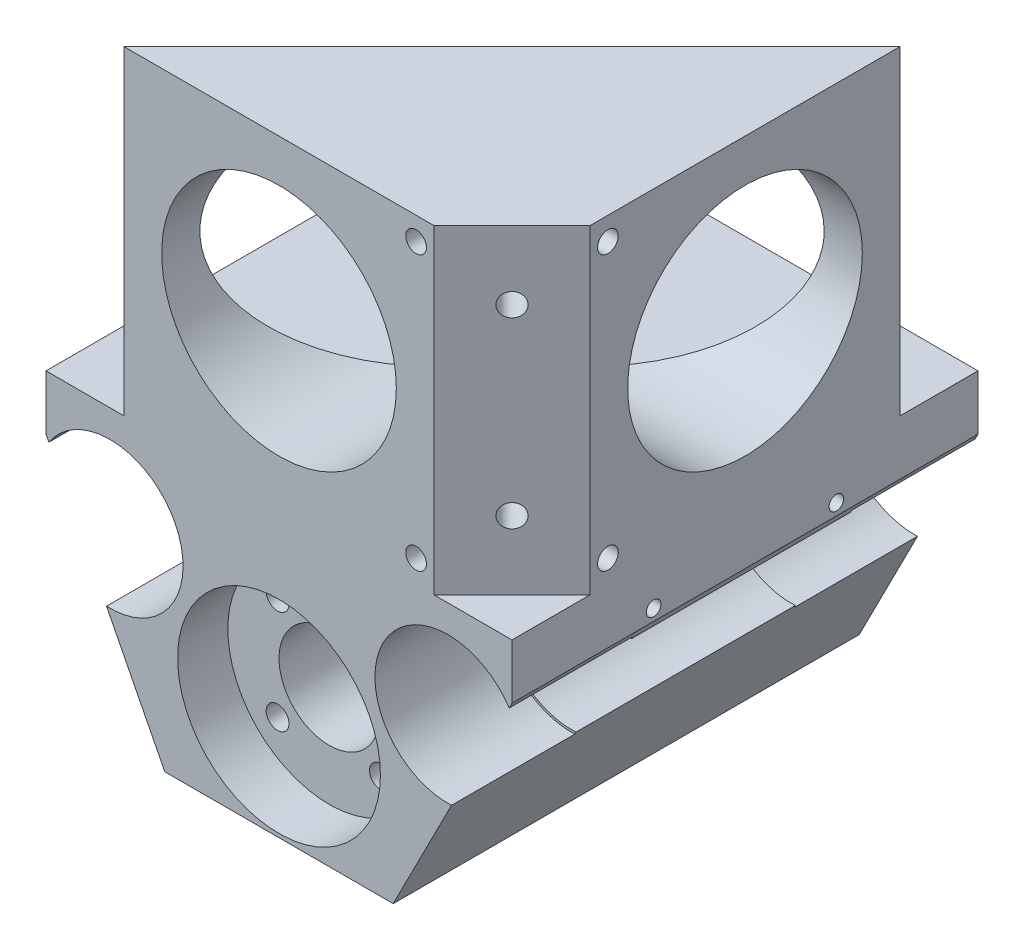
from build123d import *

# Parameters (mm, degrees)
BOSS_EXTRUDE1_DEPTH        = 51
CUT_EXTRUDE1_REACH         = 53
SKETCH2_R                  = 7.75
CUT_EXTRUDE2_REACH         = 53
SKETCH6_R                  = 5.5
M3_TAPPED_HOLE2_D          = 2.5
M3_TAPPED_HOLE2_DEPTH      = 11.5
M3_TAPPED_HOLE2_TIP        = 0.751075774
SKETCH13_R                 = 10.5
CUT_EXTRUDE5_DEPTH         = 15
BOSS_EXTRUDE2_DEPTH        = 35
CUT_EXTRUDE6_REACH         = 53
SKETCH24_R                 = 12.8397
CUT_EXTRUDE7_REACH         = 53
SKETCH25_R                 = 12.8397
M2_TAPPED_HOLE1_D          = 1.6
M2_TAPPED_HOLE1_DEPTH      = 3.2
M2_TAPPED_HOLE1_TIP        = 0.480688495
M3_TAPPED_HOLE4_D          = 2.5
M3_TAPPED_HOLE4_DEPTH      = 7.5
M3_TAPPED_HOLE4_TIP        = 0.751075774
M2_TAPPED_HOLE2_AT_2_COUNT = 2
M2_TAPPED_HOLE2_AT_2_PITCH = 20
SKETCH38_R                 = 11.1
CUT_EXTRUDE8_DEPTH         = 5.5
SKETCH39_R                 = 8
CUT_EXTRUDE9_DEPTH         = 13.5
SKETCH41_R                 = 8
CUT_EXTRUDE10_DEPTH        = 13.5
F_4_40_TAPPED_HOLE1_D      = 2.2606
F_4_40_TAPPED_HOLE1_DEPTH  = 7.59
F_4_40_TAPPED_HOLE1_TIP    = 0.679152758
F_4_40_TAPPED_HOLE2_D      = 2.2606
F_4_40_TAPPED_HOLE2_DEPTH  = 7.6
F_4_40_TAPPED_HOLE2_TIP    = 0.679152758


with BuildPart() as part:
    # Sketch1 → Boss-Extrude1 (new body)
    with BuildSketch(Plane.XY):
        Polygon((-25.5, 0), (25.5, 0), (25.5, -6), (12.5, -31.5), (-12.5, -31.5), (-25.5, -6), align=None)
    extrude(amount=BOSS_EXTRUDE1_DEPTH)

    # Sketch2 → Cut-Extrude1 (cut, up to next)
    with BuildSketch(Plane.XY.offset(51), mode=Mode.PRIVATE) as cut_extrude1_sk1:
        with Locations((-18.5, -11)):
            Circle(SKETCH2_R)
    cut_extrude1_tool1 = extrude(cut_extrude1_sk1.sketch, amount=-CUT_EXTRUDE1_REACH, mode=Mode.PRIVATE) & part.part
    add(cut_extrude1_tool1.solids().sort_by_distance((-18.5, -11, 51))[0], mode=Mode.SUBTRACT)
    # Sketch2 → Cut-Extrude1 (cut, up to next)
    with BuildSketch(Plane.XY.offset(51), mode=Mode.PRIVATE) as cut_extrude1_sk2:
        with Locations((18.5, -11)):
            Circle(SKETCH2_R)
    cut_extrude1_tool2 = extrude(cut_extrude1_sk2.sketch, amount=-CUT_EXTRUDE1_REACH, mode=Mode.PRIVATE) & part.part
    add(cut_extrude1_tool2.solids().sort_by_distance((18.5, -11, 51))[0], mode=Mode.SUBTRACT)

    # Sketch6 → Cut-Extrude2 (cut, up to next)
    with BuildSketch(Plane.XY.offset(51), mode=Mode.PRIVATE) as cut_extrude2_sk1:
        with Locations((0, -20)):
            Circle(SKETCH6_R)
    cut_extrude2_tool1 = extrude(cut_extrude2_sk1.sketch, amount=-CUT_EXTRUDE2_REACH, mode=Mode.PRIVATE) & part.part
    add(cut_extrude2_tool1.solids().sort_by_distance((0, -20, 51))[0], mode=Mode.SUBTRACT)

    # M3 Tapped Hole2
    with Locations(Plane.XY.offset(51)):
        with Locations((-5.656854249, -14.343145751), (5.656854249, -25.656854249), (5.656854249, -14.343145751), (-5.656854249, -25.656854249)):
            Hole(M3_TAPPED_HOLE2_D / 2, depth=M3_TAPPED_HOLE2_DEPTH)
            with Locations((0, 0, -(M3_TAPPED_HOLE2_DEPTH + M3_TAPPED_HOLE2_TIP / 2))):  # 118° drill point
                Cone(0, M3_TAPPED_HOLE2_D / 2, M3_TAPPED_HOLE2_TIP, mode=Mode.SUBTRACT)

    # Sketch13 → Cut-Extrude5 (cut)
    with BuildSketch(Plane(origin=(0, 0, 0), x_dir=(-1, 0, 0), z_dir=(0, 0, -1))):
        with Locations((0, -20)):
            Circle(SKETCH13_R)
    extrude(amount=-CUT_EXTRUDE5_DEPTH, mode=Mode.SUBTRACT)

    # Sketch22 → Boss-Extrude2 (add)
    with BuildSketch(Plane(origin=(0, 0, 0), x_dir=(1, 0, 0), z_dir=(0, 1, 0))):
        Polygon((-16.970562748, -50.955844123), (-16.970562748, -51), (16.970562748, -51), (25.5, -42.470562748), (25.5, -8.529437252), (25.455844123, -8.529437252), align=None)
    extrude(amount=BOSS_EXTRUDE2_DEPTH)

    # Sketch24 → Cut-Extrude6 (cut, up to next)
    with BuildSketch(Plane.XY.offset(51), mode=Mode.PRIVATE) as cut_extrude6_sk1:
        with Locations((0, 17.5)):
            Circle(SKETCH24_R)
    cut_extrude6_tool1 = extrude(cut_extrude6_sk1.sketch, amount=-CUT_EXTRUDE6_REACH, mode=Mode.PRIVATE) & part.part
    add(cut_extrude6_tool1.solids().sort_by_distance((0, 17.5, 51))[0], mode=Mode.SUBTRACT)

    # Sketch25 → Cut-Extrude7 (cut, up to next)
    with BuildSketch(Plane(origin=(25.5, 0, 0), x_dir=(0, 0, -1), z_dir=(1, 0, 0)), mode=Mode.PRIVATE) as cut_extrude7_sk1:
        with Locations((-25.5, 17.5)):
            Circle(SKETCH25_R)
    cut_extrude7_tool1 = extrude(cut_extrude7_sk1.sketch, amount=-CUT_EXTRUDE7_REACH, mode=Mode.PRIVATE) & part.part
    add(cut_extrude7_tool1.solids().sort_by_distance((25.5, 17.5, 25.5))[0], mode=Mode.SUBTRACT)

    # M2 Tapped Hole1
    with Locations(Plane(origin=(16.992640687, 0, 16.992640687), x_dir=(-0.707106781, 0, 0.707106781), z_dir=(-0.707106781, 0, -0.707106781))):
        with Locations((43.03122292, 29.5), (-6.96877708, 5.5), (-6.96877708, 29.5), (43.03122292, 5.5)):
            Hole(M2_TAPPED_HOLE1_D / 2, depth=M2_TAPPED_HOLE1_DEPTH)
            with Locations((0, 0, -(M2_TAPPED_HOLE1_DEPTH + M2_TAPPED_HOLE1_TIP / 2))):  # 118° drill point
                Cone(0, M2_TAPPED_HOLE1_D / 2, M2_TAPPED_HOLE1_TIP, mode=Mode.SUBTRACT)

    # M3 Tapped Hole4
    with Locations(Plane(origin=(33.985281374, 0, 33.985281374), x_dir=(0.707106781, 0, -0.707106781), z_dir=(0.707106781, 0, 0.707106781))):
        with Locations((-18.03122292, 27.5), (-18.03122292, 7.5)):
            Hole(M3_TAPPED_HOLE4_D / 2, depth=M3_TAPPED_HOLE4_DEPTH)
            with Locations((0, 0, -(M3_TAPPED_HOLE4_DEPTH + M3_TAPPED_HOLE4_TIP / 2))):  # 118° drill point
                Cone(0, M3_TAPPED_HOLE4_D / 2, M3_TAPPED_HOLE4_TIP, mode=Mode.SUBTRACT)

    # Sketch36 → M2 Tapped Hole2 (revolve, cut)
    with BuildSketch(Plane(origin=(25.5, -4.75, 35.5), x_dir=(0, 0, -1), z_dir=(0, 1, 0))):
        Polygon((0, 0), (0, 7.680688495), (0.8, 7.2), (0.8, 0), align=None)
    m2_tapped_hole2 = revolve(axis=Axis((31.85, -4.75, 35.5), (-1, 0, 0)), mode=Mode.SUBTRACT)

    # M2 Tapped Hole2 at 2: M2 Tapped Hole2 ×2
    with Locations(*[(0, 0, -i * M2_TAPPED_HOLE2_AT_2_PITCH) for i in range(1, M2_TAPPED_HOLE2_AT_2_COUNT)]):
        add(m2_tapped_hole2, mode=Mode.SUBTRACT)

    # Mirror1: M2 Tapped Hole2 across plane
    add(m2_tapped_hole2.mirror(Plane(origin=(0, 0, 0), x_dir=(0, 0, 1), z_dir=(1, 0, 0))), mode=Mode.SUBTRACT)

    # Mirror1 copy 1 sketch → Mirror1 copy 1 (revolve, cut)
    with BuildSketch(Plane(origin=(-25.5, -4.75, 15.5), x_dir=(0, 0, -1), z_dir=(0, 1, 0))):
        Polygon((0, 0), (0, -7.680688495), (0.8, -7.2), (0.8, 0), align=None)
    revolve(axis=Axis((-31.85, -4.75, 15.5), (-1, 0, 0)), mode=Mode.SUBTRACT)

    # Sketch38 → Cut-Extrude8 (cut)
    with BuildSketch(Plane.XY.offset(51)):
        with Locations((0, -20)):
            Circle(SKETCH38_R)
    extrude(amount=-CUT_EXTRUDE8_DEPTH, mode=Mode.SUBTRACT)

    # Sketch39 → Cut-Extrude9 (cut)
    with BuildSketch(Plane(origin=(0, 0, 0), x_dir=(-1, 0, 0), z_dir=(0, 0, -1))):
        with Locations((18.5, -11)):
            Circle(SKETCH39_R)
        with Locations((-18.5, -11)):
            Circle(SKETCH39_R)
    extrude(amount=-CUT_EXTRUDE9_DEPTH, mode=Mode.SUBTRACT)

    # Sketch41 → Cut-Extrude10 (cut)
    with BuildSketch(Plane.XY.offset(51)):
        with Locations((18.5, -11)):
            Circle(SKETCH41_R)
        with Locations((-18.5, -11)):
            Circle(SKETCH41_R)
    extrude(amount=-CUT_EXTRUDE10_DEPTH, mode=Mode.SUBTRACT)

    # #4-40 Tapped Hole1
    with Locations(Plane(origin=(25.5, 0, 0), x_dir=(0, 0, -1), z_dir=(1, 0, 0))):
        with Locations((-40.5, 32.5), (-40.5, 2.5)):
            Hole(F_4_40_TAPPED_HOLE1_D / 2, depth=F_4_40_TAPPED_HOLE1_DEPTH)
            with Locations((0, 0, -(F_4_40_TAPPED_HOLE1_DEPTH + F_4_40_TAPPED_HOLE1_TIP / 2))):  # 118° drill point
                Cone(0, F_4_40_TAPPED_HOLE1_D / 2, F_4_40_TAPPED_HOLE1_TIP, mode=Mode.SUBTRACT)

    # #4-40 Tapped Hole2
    with Locations(Plane.XY.offset(51)):
        with Locations((15, 32.5), (15, 2.5)):
            Hole(F_4_40_TAPPED_HOLE2_D / 2, depth=F_4_40_TAPPED_HOLE2_DEPTH)
            with Locations((0, 0, -(F_4_40_TAPPED_HOLE2_DEPTH + F_4_40_TAPPED_HOLE2_TIP / 2))):  # 118° drill point
                Cone(0, F_4_40_TAPPED_HOLE2_D / 2, F_4_40_TAPPED_HOLE2_TIP, mode=Mode.SUBTRACT)


solid = part.part
